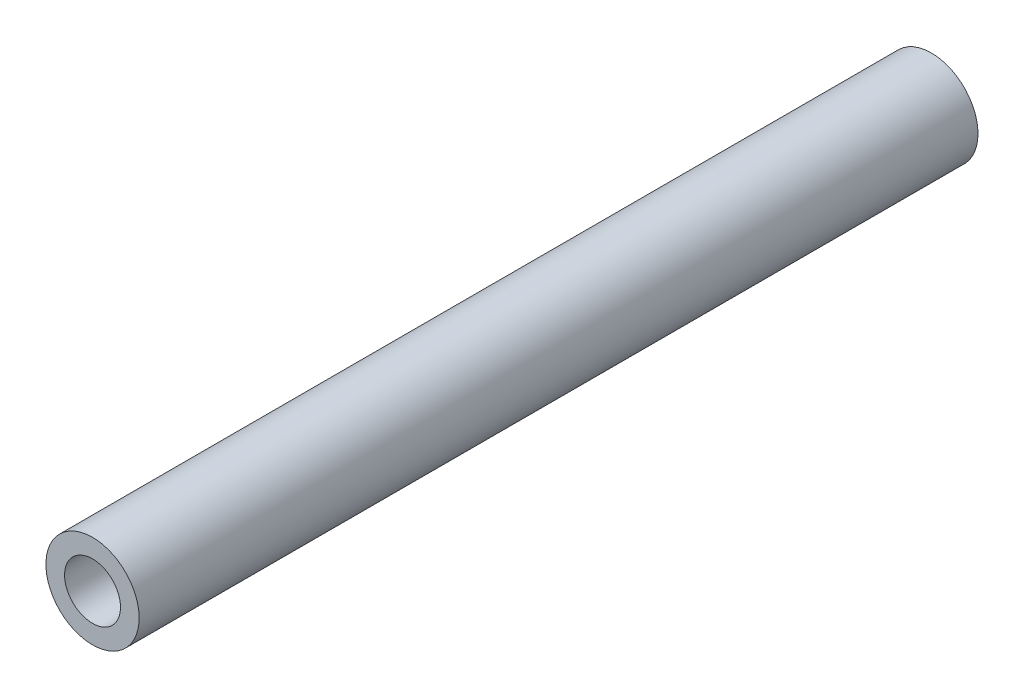
from build123d import *

# Parameters (mm, degrees)
SKETCH_1_R      = 2.5
SKETCH_1_R_2    = 1.5
EXTRUDE_1_DEPTH = 22.5


with BuildPart() as part:
    # 草图1 → 凸台-拉伸1 (new body, symmetric)
    with BuildSketch(Plane.XY):
        Circle(SKETCH_1_R)
        Circle(SKETCH_1_R_2, mode=Mode.SUBTRACT)
    extrude(amount=EXTRUDE_1_DEPTH, both=True)


solid = part.part
